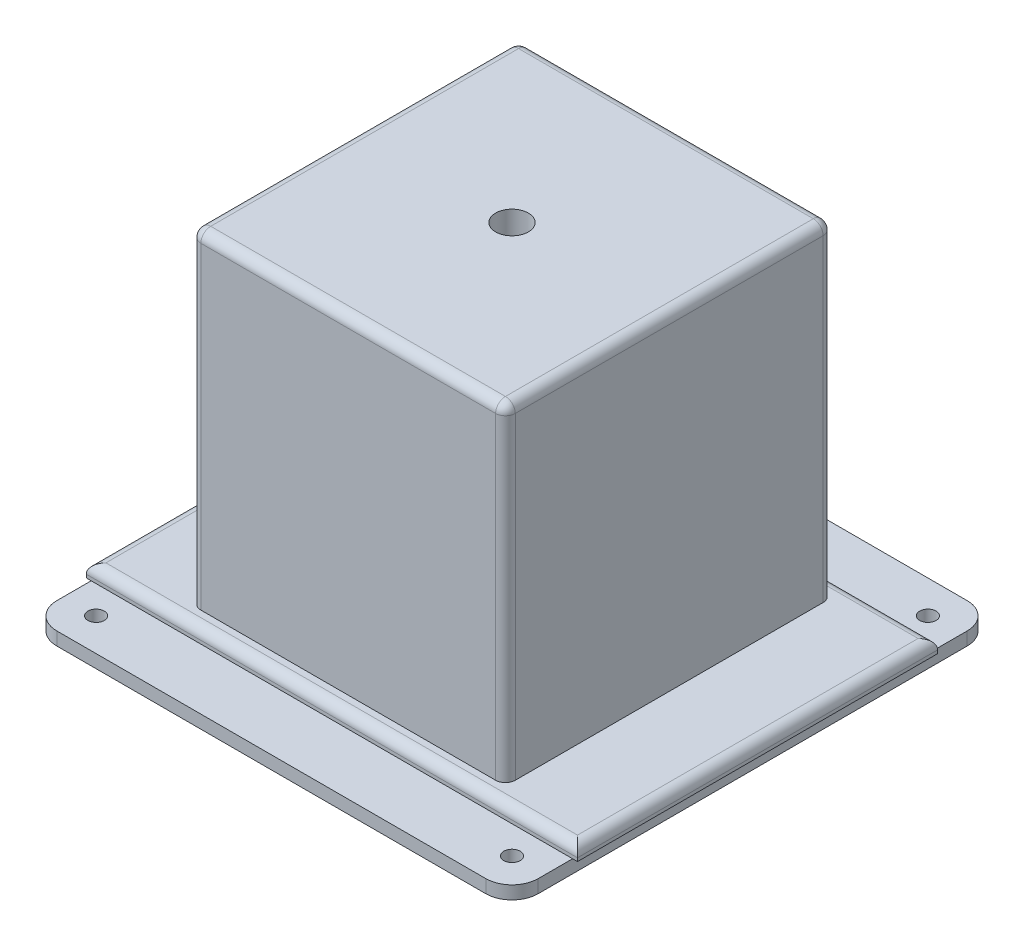
from build123d import *

# Parameters (mm, degrees)
SKETCH1_W           = 150
SKETCH1_H           = 110
BOSS_EXTRUDE1_DEPTH = 4
SKETCH2_W           = 96
SKETCH2_H           = 100
BOSS_EXTRUDE2_DEPTH = 100
FILLET1_R           = 3
SKETCH4_R           = 5
CUT_EXTRUDE1_DEPTH  = 15
SKETCH5_W           = 147
SKETCH5_H           = 147
BOSS_EXTRUDE3_DEPTH = 4
SKETCH6_R           = 2.5
CUT_EXTRUDE2_DEPTH  = 5
FILLET2_R           = 8


with BuildPart() as part:
    # Sketch1 → Boss-Extrude1 (new body)
    with BuildSketch(Plane(origin=(0, 0, 0), x_dir=(1, 0, 0), z_dir=(0, 1, 0))):
        with Locations((75, 55)):
            Rectangle(SKETCH1_W, SKETCH1_H)
    extrude(amount=BOSS_EXTRUDE1_DEPTH)

    # Sketch2 → Boss-Extrude2 (add)
    with BuildSketch(Plane(origin=(0, 4, 0), x_dir=(1, 0, 0), z_dir=(0, 1, 0))):
        with Locations((75, 55)):
            Rectangle(SKETCH2_W, SKETCH2_H)
    extrude(amount=BOSS_EXTRUDE2_DEPTH)

    # Fillet1
    fillet1_edges = [part.edges().sort_by_distance(p)[0] for p in [
        (150, 4, -55),
        (27, 54, -105),
        (27, 54, -5),
        (75, 4, -110),
        (123, 54, -5),
        (123, 54, -105),
        (27, 104, -55),
        (75, 104, -5),
        (123, 104, -55),
        (75, 104, -105),
        (0, 4, -55),
        (75, 4, 0),
    ]]
    fillet(fillet1_edges, radius=FILLET1_R)

    # Sketch4 → Cut-Extrude1 (cut)
    with BuildSketch(Plane(origin=(0, 104, 0), x_dir=(1, 0, 0), z_dir=(0, 1, 0))):
        with Locations((75, 55)):
            Circle(SKETCH4_R)
    extrude(amount=-CUT_EXTRUDE1_DEPTH, mode=Mode.SUBTRACT)

    # Sketch5 → Boss-Extrude3 (add)
    with BuildSketch(Plane.XZ):
        with Locations((75, -55)):
            Rectangle(SKETCH5_W, SKETCH5_H)
    extrude(amount=BOSS_EXTRUDE3_DEPTH)

    # Sketch6 → Cut-Extrude2 (cut, through all)
    with BuildSketch(Plane(origin=(0, 0, 0), x_dir=(1, 0, 0), z_dir=(0, 1, 0))):
        with Locations((11.5, 118.5)):
            Circle(SKETCH6_R)
        with Locations((138.5, 118.5)):
            Circle(SKETCH6_R)
        with Locations((11.5, -8.5)):
            Circle(SKETCH6_R)
        with Locations((138.5, -8.5)):
            Circle(SKETCH6_R)
    extrude(amount=-CUT_EXTRUDE2_DEPTH, mode=Mode.SUBTRACT)

    # Fillet2
    fillet2_edges = [part.edges().sort_by_distance(p)[0] for p in [
        (1.5, -2, 18.5),
        (1.5, -2, -128.5),
        (148.5, -2, -128.5),
        (148.5, -2, 18.5),
    ]]
    fillet(fillet2_edges, radius=FILLET2_R)


solid = part.part
